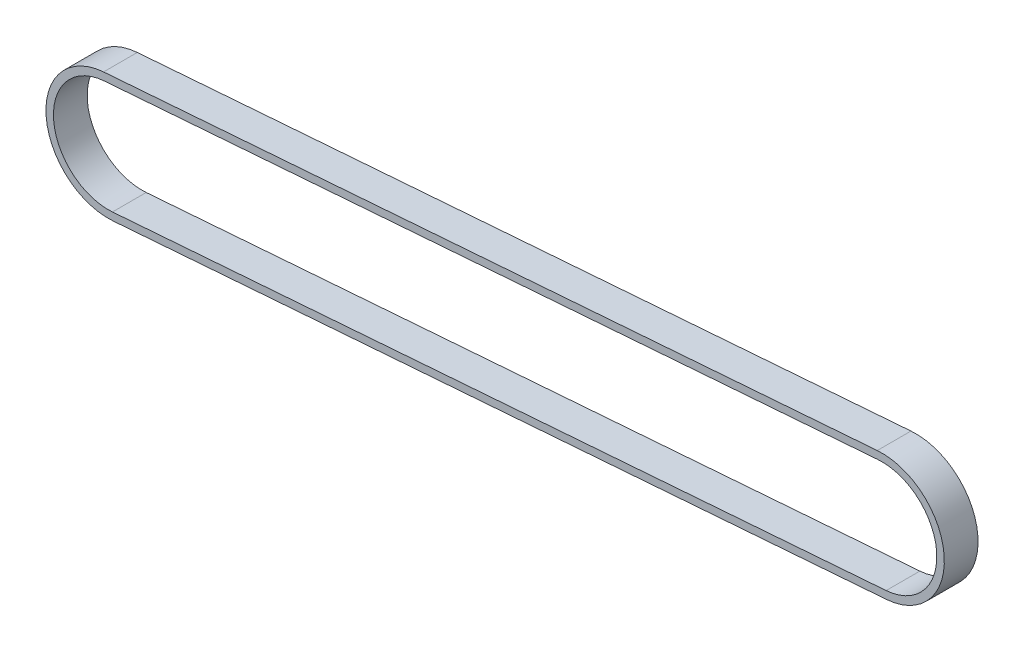
from build123d import *

# Parameters (mm, degrees)
EXTRUDE_THIN2_DEPTH = 11.382736928


with BuildPart() as part:
    # Sketch2 → Extrude-Thin2 (new body)
    with BuildSketch(Plane.XY):
        with BuildLine():
            Line((262.464499147, -0.950118607), (1.371234696, -20.853238053))
            ThreePointArc((1.371234696, -20.853238053), (-21.20713644, -1.473342366), (-1.827240753, 21.105028771))
            Line((-1.827240753, 21.105028771), (259.266023698, 41.008148216))
            ThreePointArc((259.266023698, 41.008148216), (281.844394834, 21.628252529), (262.464499147, -0.950118607))
        make_face()
        with BuildLine():
            Line((262.271435277, 1.58253343), (1.178170826, -18.320586015))
            ThreePointArc((1.178170826, -18.320586015), (-18.674484403, -1.280278496), (-1.634176883, 18.572376733))
            Line((-1.634176883, 18.572376733), (259.459087568, 38.475496178))
            ThreePointArc((259.459087568, 38.475496178), (279.311742797, 21.435188659), (262.271435277, 1.58253343))
        make_face(mode=Mode.SUBTRACT)
    extrude(amount=EXTRUDE_THIN2_DEPTH)


solid = part.part
